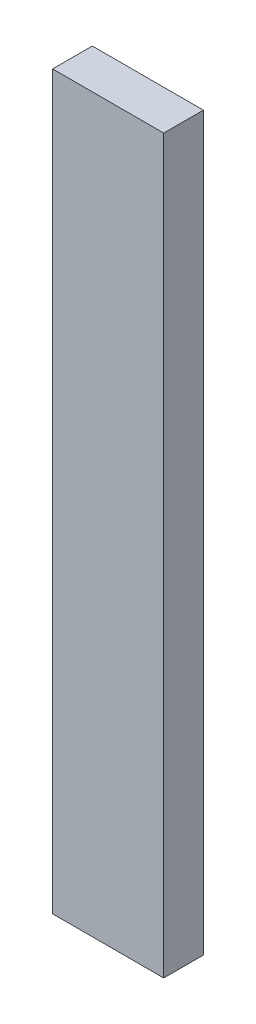
from build123d import *

# Parameters (mm, degrees)
SKETCH1_W           = 0.7
SKETCH1_H           = 0.25
BOSS_EXTRUDE1_DEPTH = 4.61


with BuildPart() as part:
    # Sketch1 → Boss-Extrude1 (new body)
    with BuildSketch(Plane(origin=(0, 0, 0), x_dir=(1, 0, 0), z_dir=(0, 1, 0))):
        Rectangle(SKETCH1_W, SKETCH1_H)
    extrude(amount=BOSS_EXTRUDE1_DEPTH)


solid = part.part
